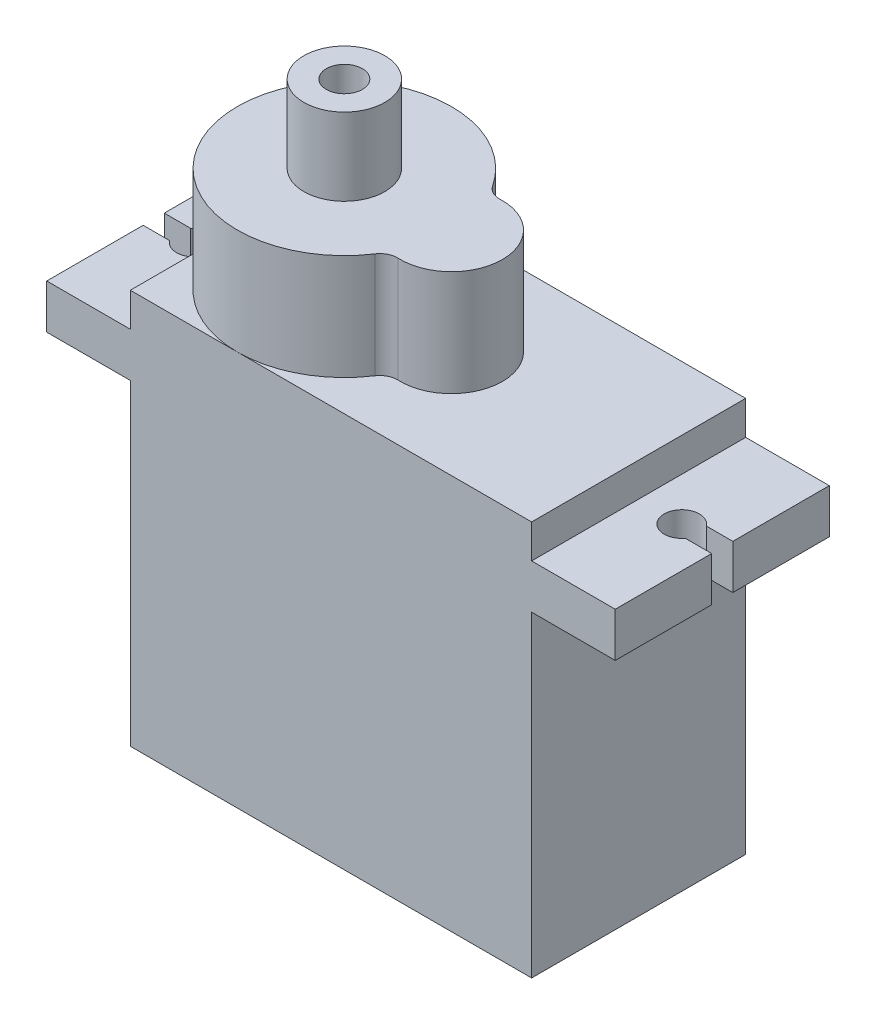
from build123d import *

# Parameters (mm, degrees)
SKETCH_1_W               = 22.8
SKETCH_1_H               = 12.16
EXTRUDE_1_DEPTH          = 22.44
EXTRUDE_START            = 18
SKETCH_3_W               = 32.3
SKETCH_3_H               = 12.16
EXTRUDE_2_DEPTH          = 2.52
EXTRUDE_3_DEPTH          = 6
FILLET_1_R               = 1
CUT_EXTRUDE_1_REACH      = 28.812
SKETCH_6_R               = 2.3
EXTRUDE_4_DEPTH          = 4.39
HOLE_WIZARD_M2_5_1_D     = 2.05
HOLE_WIZARD_M2_5_1_DEPTH = 4.39
HOLE_WIZARD_M2_5_1_TIP   = 0.615882135
SKETCH_10_W              = 3.6
SKETCH_10_H              = 1.3
EXTRUDE_5_DEPTH          = 2


with BuildPart() as part:
    # 草图1 → 凸台-拉伸1 (new body)
    with BuildSketch(Plane(origin=(0, 0, 0), x_dir=(1, 0, 0), z_dir=(0, 1, 0))):
        Rectangle(SKETCH_1_W, SKETCH_1_H)
    extrude(amount=EXTRUDE_1_DEPTH)

    # 草图3 → 凸台-拉伸2 (add)
    with BuildSketch(Plane(origin=(0, 0, 0), x_dir=(1, 0, 0), z_dir=(0, 1, 0)).offset(EXTRUDE_START)):
        Rectangle(SKETCH_3_W, SKETCH_3_H)
    extrude(amount=EXTRUDE_2_DEPTH)

    # 草图4 → 凸台-拉伸3 (add)
    with BuildSketch(Plane(origin=(0, 22.44, 0), x_dir=(1, 0, 0), z_dir=(0, 1, 0))):
        with BuildLine():
            ThreePointArc((0.068388158, -2.816322613), (3.66, 0), (0.068388158, 2.816322613))
            ThreePointArc((0.068388158, 2.816322613), (-11.4, 0), (0.068388158, -2.816322613))
        make_face()
    extrude(amount=EXTRUDE_3_DEPTH)

    # 圆角1
    fillet_1_edges = [part.edges().sort_by_distance(p)[0] for p in [
        (0.068388158, 25.44, -2.816322613),
        (0.068388158, 25.44, 2.816322613),
    ]]
    fillet(fillet_1_edges, radius=FILLET_1_R)

    # 草图5 → 切除-拉伸1 (cut, up to next)
    with BuildSketch(Plane(origin=(0, 20.52, 0), x_dir=(1, 0, 0), z_dir=(0, 1, 0)), mode=Mode.PRIVATE) as cut_extrude_1_sk1:
        with BuildLine():
            Line((-18.45, 0.6), (-18.45, -0.6))
            Line((-18.45, -0.6), (-14.65, -0.6))
            ThreePointArc((-14.65, -0.6), (-12.85, 0), (-14.65, 0.6))
            Line((-14.65, 0.6), (-18.45, 0.6))
        make_face()
    cut_extrude_1_tool1 = extrude(cut_extrude_1_sk1.sketch, amount=-CUT_EXTRUDE_1_REACH, mode=Mode.PRIVATE) & part.part
    # 草图5 → 切除-拉伸1 (cut, up to next)
    with BuildSketch(Plane(origin=(0, 20.52, 0), x_dir=(1, 0, 0), z_dir=(0, 1, 0)), mode=Mode.PRIVATE) as cut_extrude_1_sk2:
        with BuildLine():
            Line((14.65, -0.6), (18.45, -0.6))
            Line((18.45, -0.6), (18.45, 0.6))
            Line((18.45, 0.6), (14.65, 0.6))
            ThreePointArc((14.65, 0.6), (12.85, 0), (14.65, -0.6))
        make_face()
    cut_extrude_1_tool2 = extrude(cut_extrude_1_sk2.sketch, amount=-CUT_EXTRUDE_1_REACH, mode=Mode.PRIVATE) & part.part
    add(cut_extrude_1_tool1.solids().sort_by_distance((-15.464202, 20.52, 0))[0], mode=Mode.SUBTRACT)
    add(cut_extrude_1_tool2.solids().sort_by_distance((15.464202, 20.52, 0))[0], mode=Mode.SUBTRACT)

    # 草图6 → 凸台-拉伸4 (add)
    with BuildSketch(Plane(origin=(0, 28.44, 0), x_dir=(1, 0, 0), z_dir=(0, 1, 0))):
        with Locations((-5.32, 0)):
            Circle(SKETCH_6_R)
    extrude(amount=EXTRUDE_4_DEPTH)

    # M2.5 螺纹孔1
    with Locations(Plane(origin=(0, 32.83, 0), x_dir=(1, 0, 0), z_dir=(0, 1, 0))):
        with Locations((-5.32, 0)):
            Hole(HOLE_WIZARD_M2_5_1_D / 2, depth=HOLE_WIZARD_M2_5_1_DEPTH)
            with Locations((0, 0, -(HOLE_WIZARD_M2_5_1_DEPTH + HOLE_WIZARD_M2_5_1_TIP / 2))):  # 118° drill point
                Cone(0, HOLE_WIZARD_M2_5_1_D / 2, HOLE_WIZARD_M2_5_1_TIP, mode=Mode.SUBTRACT)

    # 草图10 → 凸台-拉伸5 (add)
    with BuildSketch(Plane.ZY.offset(11.4)):
        with Locations((0, 4.93)):
            Rectangle(SKETCH_10_W, SKETCH_10_H)
    extrude(amount=EXTRUDE_5_DEPTH)


solid = part.part
